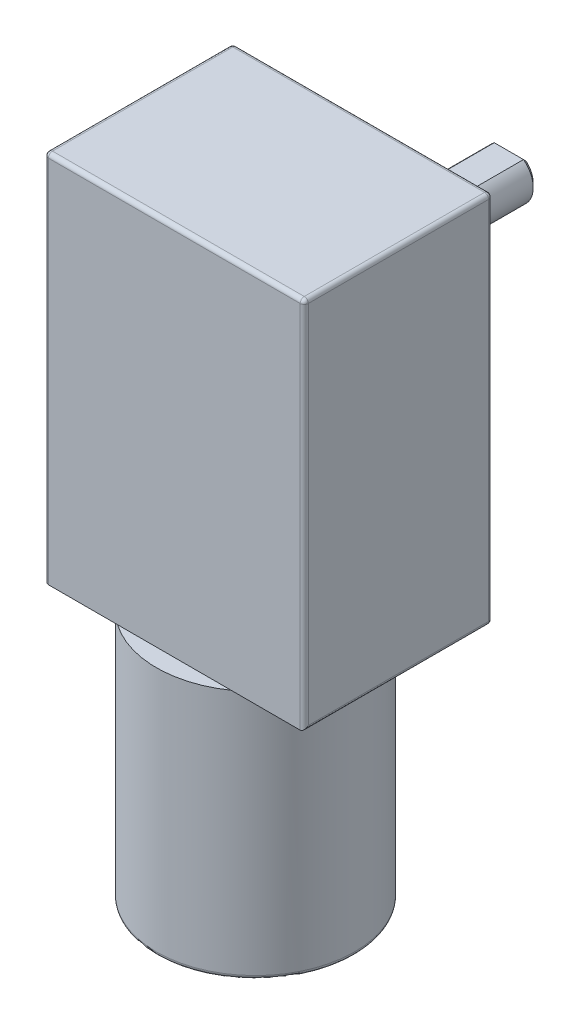
from build123d import *

# Parameters (mm, degrees)
SKETCH_1_R          = 3.5
EXTRUDE_1_DEPTH     = 3
SKETCH_2_R          = 12.2
EXTRUDE_2_DEPTH     = 30.8
SKETCH_3_W          = 32
SKETCH_3_H          = 25.2
EXTRUDE_3_DEPTH     = 46
SKETCH_4_R          = 3
EXTRUDE_4_DEPTH     = 16.5
CUT_EXTRUDE_1_DEPTH = 12
SKETCH_6_W          = 32
SKETCH_6_H          = 46
SKETCH_6_R          = 6.5
SKETCH_6_R_2        = 3
CUT_EXTRUDE_2_DEPTH = 2
FILLET_1_R          = 0.5
CHAMFER_1_SIZE      = 0.5
CHAMFER_2_SIZE      = 0.5
SKETCH_7_R          = 1.6
CUT_EXTRUDE_3_DEPTH = 4
FILLET_2_R          = 0.5


with BuildPart() as part:
    # Эскиз1 → Бобышка-Вытянуть1 (new body)
    with BuildSketch(Plane(origin=(0, 0, 0), x_dir=(1, 0, 0), z_dir=(0, 1, 0))):
        Circle(SKETCH_1_R)
    extrude(amount=EXTRUDE_1_DEPTH)

    # Эскиз2 → Бобышка-Вытянуть2 (add)
    with BuildSketch(Plane(origin=(0, 3, 0), x_dir=(1, 0, 0), z_dir=(0, 1, 0))):
        Circle(SKETCH_2_R)
    extrude(amount=EXTRUDE_2_DEPTH)

    # Эскиз3 → Бобышка-Вытянуть3 (add)
    with BuildSketch(Plane(origin=(0, 33.8, 0), x_dir=(1, 0, 0), z_dir=(0, 1, 0))):
        with Locations((0, 2.6)):
            Rectangle(SKETCH_3_W, SKETCH_3_H)
    extrude(amount=EXTRUDE_3_DEPTH)

    # Эскиз4 → Бобышка-Вытянуть4 (add)
    with BuildSketch(Plane(origin=(0, 0, -15.2), x_dir=(-1, 0, 0), z_dir=(0, 0, -1))):
        with Locations((0, 64.8)):
            Circle(SKETCH_4_R)
    extrude(amount=EXTRUDE_4_DEPTH)

    # Эскиз5 → Вырез-Вытянуть1 (cut)
    with BuildSketch(Plane(origin=(0, 0, -31.7), x_dir=(-1, 0, 0), z_dir=(0, 0, -1))):
        with BuildLine():
            Line((-1.8, 67.2), (1.8, 67.2))
            ThreePointArc((1.8, 67.2), (0, 67.8), (-1.8, 67.2))
        make_face()
    extrude(amount=-CUT_EXTRUDE_1_DEPTH, mode=Mode.SUBTRACT)

    # Эскиз6 → Вырез-Вытянуть2 (cut)
    with BuildSketch(Plane(origin=(0, 0, -15.2), x_dir=(-1, 0, 0), z_dir=(0, 0, -1))):
        with Locations((0, 56.8)):
            Rectangle(SKETCH_6_W, SKETCH_6_H)
        with Locations((0, 64.8)):
            Circle(SKETCH_6_R, mode=Mode.SUBTRACT)
        with Locations((9, 40.8)):
            Circle(SKETCH_6_R_2, mode=Mode.SUBTRACT)
        with Locations((-9, 40.8)):
            Circle(SKETCH_6_R_2, mode=Mode.SUBTRACT)
        with Locations((-9, 73.8)):
            Circle(SKETCH_6_R_2, mode=Mode.SUBTRACT)
        with Locations((9, 73.8)):
            Circle(SKETCH_6_R_2, mode=Mode.SUBTRACT)
        with BuildLine():
            ThreePointArc((4.167925211, 49.8), (7.167925211, 52.8), (4.167925211, 55.8))
            Line((4.167925211, 55.8), (-4.167925211, 55.8))
            ThreePointArc((-4.167925211, 55.8), (-7.167925211, 52.8), (-4.167925211, 49.8))
            Line((-4.167925211, 49.8), (4.167925211, 49.8))
        make_face(mode=Mode.SUBTRACT)
    extrude(amount=-CUT_EXTRUDE_2_DEPTH, mode=Mode.SUBTRACT)

    # Скругление1
    fillet_1_edges = [part.edges().sort_by_distance(p)[0] for p in [
        (-7.167925211, 52.8, -15.2),
        (7.167925211, 52.8, -15.2),
        (-6, 73.8, -15.2),
        (12, 73.8, -15.2),
        (12, 40.8, -15.2),
        (6.5, 64.8, -15.2),
        (0, 49.8, -15.2),
        (6.5, 64.8, -13.2),
        (-6, 40.8, -13.2),
        (0, 55.8, -15.2),
    ]]
    fillet(fillet_1_edges, radius=FILLET_1_R)

    # Фаска1
    chamfer_1_edges = [part.edges().sort_by_distance(p)[0] for p in [
        (1.341640786, 62.116718427, -31.7),
    ]]
    chamfer(chamfer_1_edges, length=CHAMFER_1_SIZE)

    # Фаска2
    chamfer_2_edges = [part.edges().sort_by_distance(p)[0] for p in [
        (0, 67.2, -31.7),
    ]]
    chamfer(chamfer_2_edges, length=CHAMFER_2_SIZE)

    # Эскиз7 → Вырез-Вытянуть3 (cut)
    with BuildSketch(Plane(origin=(0, 0, -15.2), x_dir=(-1, 0, 0), z_dir=(0, 0, -1))):
        with Locations((9, 73.8)):
            Circle(SKETCH_7_R)
        with Locations((-9, 73.8)):
            Circle(SKETCH_7_R)
        with Locations((-9, 40.8)):
            Circle(SKETCH_7_R)
        with Locations((9, 40.8)):
            Circle(SKETCH_7_R)
    extrude(amount=-CUT_EXTRUDE_3_DEPTH, mode=Mode.SUBTRACT)

    # Скругление2
    fillet_2_edges = [part.edges().sort_by_distance(p)[0] for p in [
        (-16, 56.8, 10),
        (16, 33.8, -1.6),
        (16, 56.8, 10),
        (0, 79.8, 10),
        (16, 79.8, -1.6),
        (-3.5, 0, 0),
        (-16, 79.8, -1.6),
        (-16, 33.8, -1.6),
        (16, 56.8, -13.2),
        (0, 79.8, -13.2),
        (-16, 56.8, -13.2),
        (0, 33.8, -13.2),
        (-12.2, 3, 0),
    ]]
    fillet(fillet_2_edges, radius=FILLET_2_R)


solid = part.part
